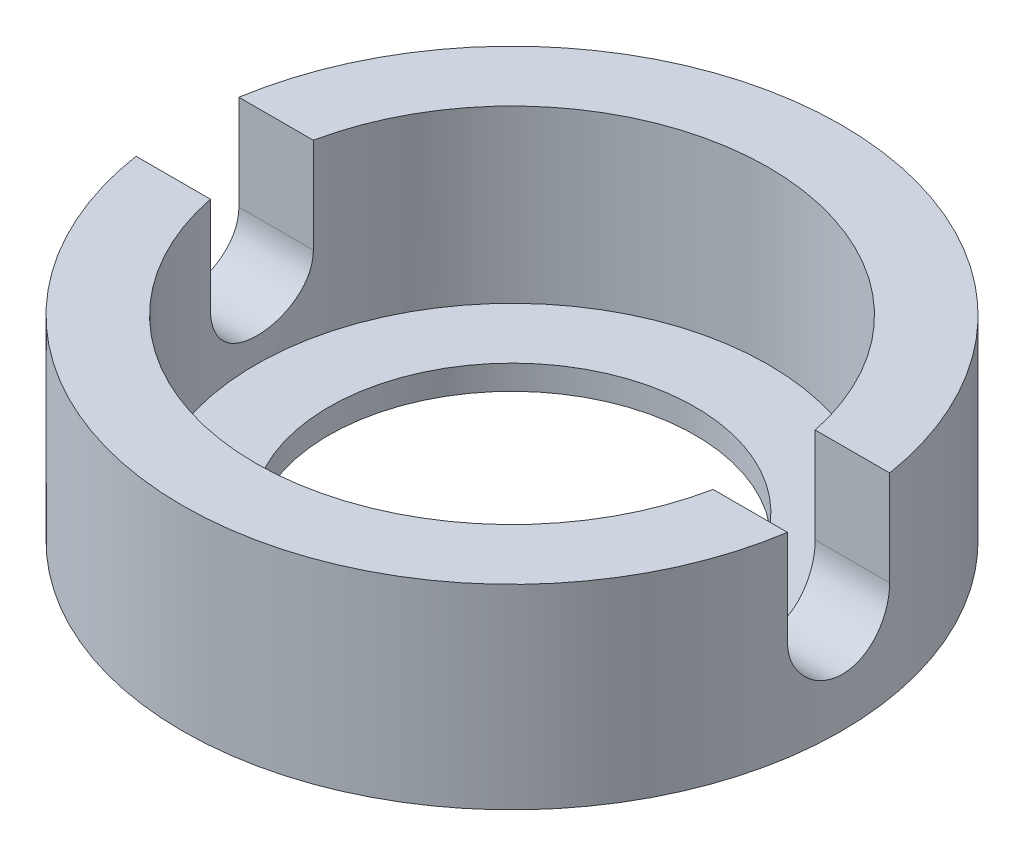
from build123d import *

# Parameters (mm, degrees)
SCHIZZO1_R                    = 13.5
ESTRUSIONE_ESTRUSIONE1_DEPTH  = 8
SCHIZZO2_R                    = 10.5
TAGLIO_ESTRUSIONE1_DEPTH      = 7
SCHIZZO3_R                    = 7.5
TAGLIO_ESTRUSIONE2_DEPTH      = 2
TAGLIO_ESTRUSIONE4_DEPTH      = 14.5
TAGLIO_ESTRUSIONE4_DEPTH_BACK = 14.5


with BuildPart() as part:
    # Schizzo1 → Estrusione-Estrusione1 (new body)
    with BuildSketch(Plane(origin=(0, 0, 0), x_dir=(1, 0, 0), z_dir=(0, 1, 0))):
        Circle(SCHIZZO1_R)
    extrude(amount=ESTRUSIONE_ESTRUSIONE1_DEPTH)

    # Schizzo2 → Taglio-Estrusione1 (cut)
    with BuildSketch(Plane(origin=(0, 8, 0), x_dir=(1, 0, 0), z_dir=(0, 1, 0))):
        Circle(SCHIZZO2_R)
    extrude(amount=-TAGLIO_ESTRUSIONE1_DEPTH, mode=Mode.SUBTRACT)

    # Schizzo3 → Taglio-Estrusione2 (cut, through all)
    with BuildSketch(Plane(origin=(0, 1, 0), x_dir=(1, 0, 0), z_dir=(0, 1, 0))):
        Circle(SCHIZZO3_R)
    extrude(amount=-TAGLIO_ESTRUSIONE2_DEPTH, mode=Mode.SUBTRACT)

    # Schizzo4 → Taglio-Estrusione4 (cut, two sides)
    with BuildSketch(Plane(origin=(0, 0, 0), x_dir=(0, 0, -1), z_dir=(1, 0, 0))) as taglio_estrusione4_sk:
        with BuildLine():
            Line((2.140854023, 8), (-2.059200669, 8))
            Line((-2.059200669, 8), (-2.059200669, 4.1))
            ThreePointArc((-2.059200669, 4.1), (0.040826677, 1.999972654), (2.140854023, 4.1))
            Line((2.140854023, 4.1), (2.140854023, 8))
        make_face()
    extrude(amount=TAGLIO_ESTRUSIONE4_DEPTH, mode=Mode.SUBTRACT)
    extrude(taglio_estrusione4_sk.sketch, amount=-TAGLIO_ESTRUSIONE4_DEPTH_BACK, mode=Mode.SUBTRACT)


solid = part.part
